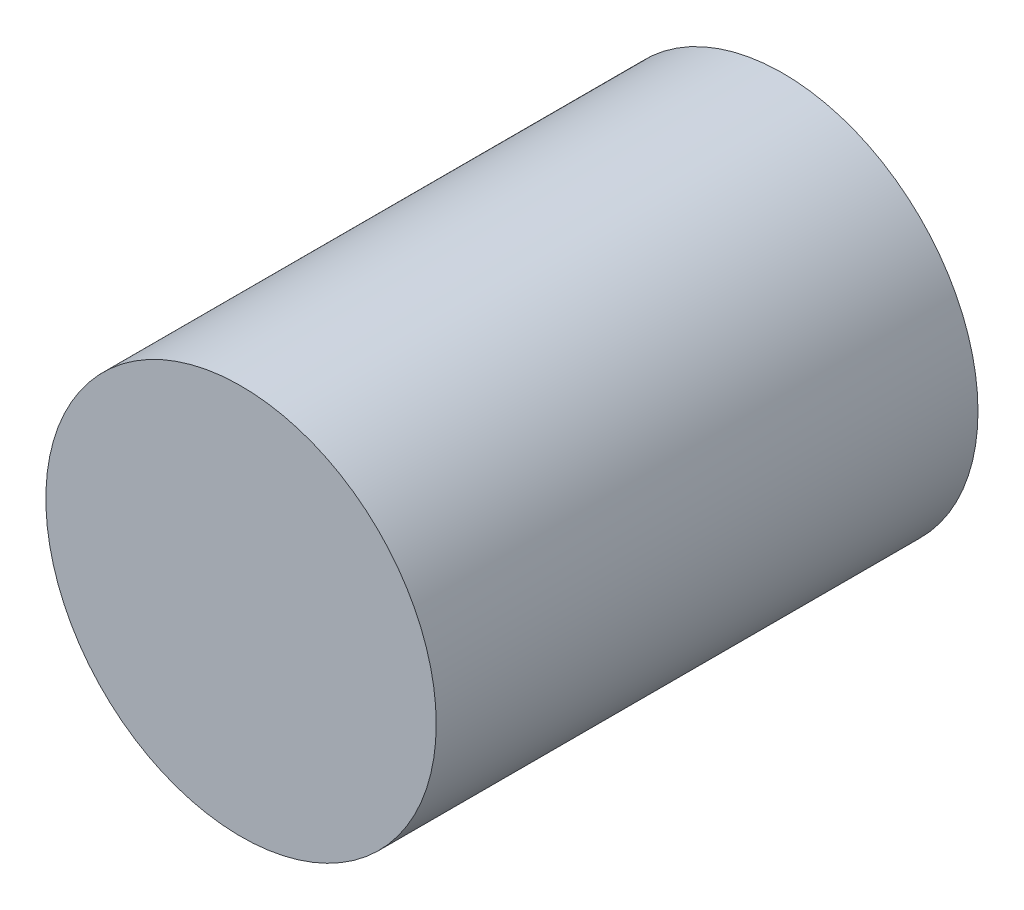
from build123d import *

# Parameters (mm, degrees)
SKETCH1_R           = 9.72312
BOSS_EXTRUDE1_DEPTH = 13.49375


with BuildPart() as part:
    # Sketch1 → Boss-Extrude1 (new body, symmetric)
    with BuildSketch(Plane.XY):
        Circle(SKETCH1_R)
    extrude(amount=BOSS_EXTRUDE1_DEPTH, both=True)


solid = part.part
